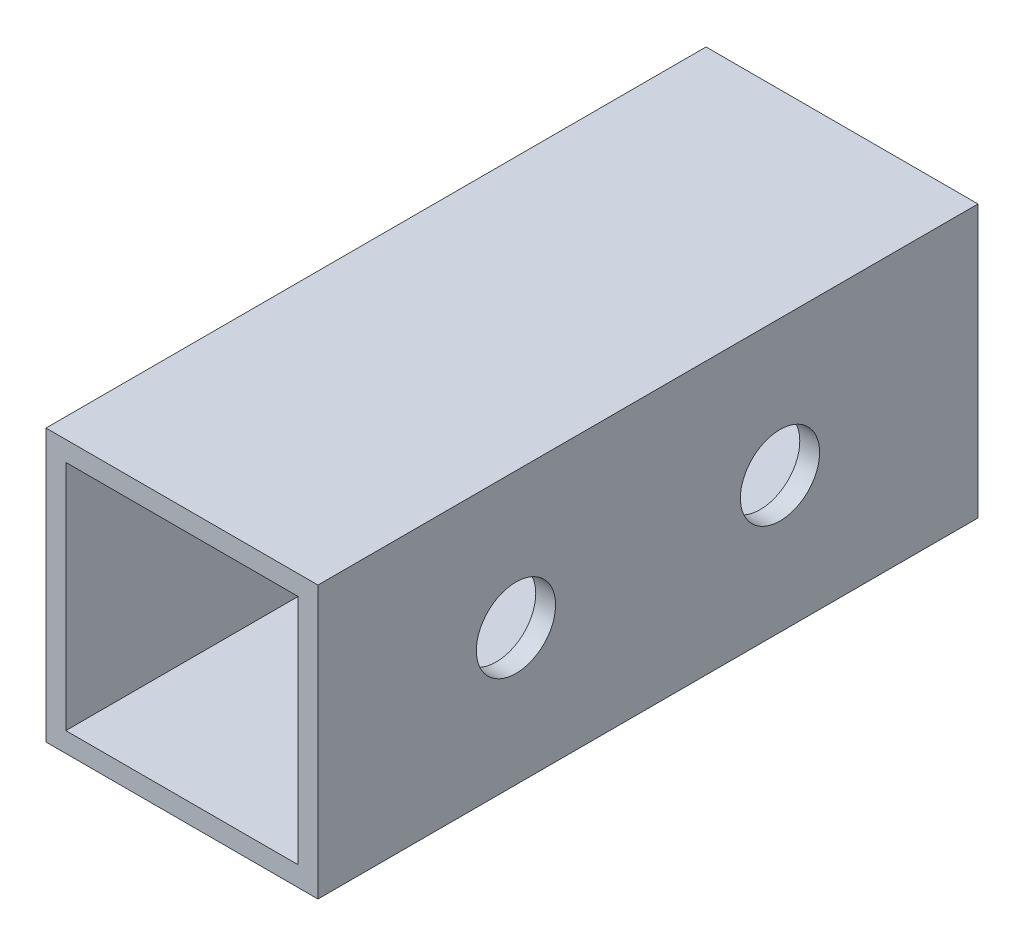
from build123d import *

# Parameters (mm, degrees)
SKETCH_1_W          = 20.6
SKETCH_1_H          = 20.6
SKETCH_1_W_2        = 17.6
SKETCH_1_H_2        = 17.6
EXTRUDE_1_DEPTH     = 50
SKETCH_2_R          = 3
CUT_EXTRUDE_1_DEPTH = 21.6


with BuildPart() as part:
    # Эскиз1 → Бобышка-Вытянуть1 (new body)
    with BuildSketch(Plane.XY):
        with Locations((-28.986771917, 9.543697479)):
            Rectangle(SKETCH_1_W, SKETCH_1_H)
        with Locations((-28.986771917, 9.543697479)):
            Rectangle(SKETCH_1_W_2, SKETCH_1_H_2, mode=Mode.SUBTRACT)
    extrude(amount=EXTRUDE_1_DEPTH)

    # Эскиз2 → Вырез-Вытянуть1 (cut, through all)
    with BuildSketch(Plane(origin=(-18.686771917, 0, 0), x_dir=(0, 0, -1), z_dir=(1, 0, 0))):
        with Locations(Location((-35, 9.543697479, 0), (0, 0, 90))):  # turned: the seam where the file's is
            Circle(SKETCH_2_R)
        with Locations(Location((-15, 9.543697479, 0), (0, 0, 90))):  # turned: the seam where the file's is
            Circle(SKETCH_2_R)
    extrude(amount=-CUT_EXTRUDE_1_DEPTH, mode=Mode.SUBTRACT)


solid = part.part
